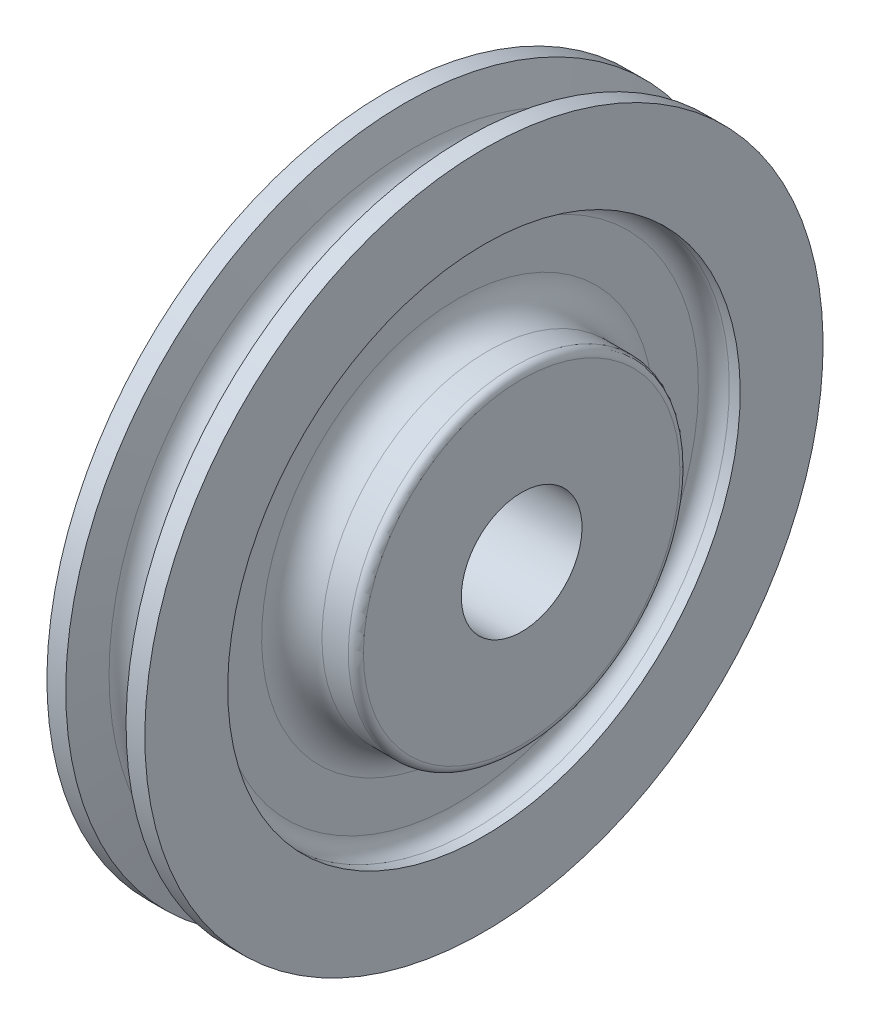
from build123d import *

# Parameters (mm, degrees)
SKETCH2_R          = 12.7127
CUT_EXTRUDE1_DEPTH = 37.5125


with BuildPart() as part:
    # Sketch1 → Revolve1 (revolve)
    with BuildSketch(Plane.XY):
        with BuildLine():
            Line((18.25625, 0), (-18.25625, 0))
            Line((-18.25625, 0), (-18.25625, 33.3375))
            ThreePointArc((-18.25625, 33.3375), (-17.791282015, 34.460032015), (-16.66875, 34.925))
            Line((-16.66875, 34.925), (-11.1125, 34.925))
            ThreePointArc((-11.1125, 34.925), (-6.622371939, 36.784871939), (-4.7625, 41.275))
            Line((-4.7625, 41.275), (-4.7625, 50.7238))
            ThreePointArc((-4.7625, 50.7238), (-5.714754433, 53.022745567), (-8.0137, 53.975))
            Line((-8.0137, 53.975), (-10.3124, 53.975))
            Line((-10.3124, 53.975), (-10.3124, 71.43115))
            Line((-10.3124, 71.43115), (-6.35, 71.43115))
            Line((-6.35, 71.43115), (-4.640755559, 64.017549491))
            ThreePointArc((-4.640755559, 64.017549491), (0, 60.325), (4.640755559, 64.017549491))
            Line((4.640755559, 64.017549491), (6.35, 71.43115))
            Line((6.35, 71.43115), (10.3124, 71.43115))
            Line((10.3124, 71.43115), (10.3124, 53.975))
            Line((10.3124, 53.975), (8.0137, 53.975))
            ThreePointArc((8.0137, 53.975), (5.714754433, 53.022745567), (4.7625, 50.7238))
            Line((4.7625, 50.7238), (4.7625, 41.275))
            ThreePointArc((4.7625, 41.275), (6.622371939, 36.784871939), (11.1125, 34.925))
            Line((11.1125, 34.925), (16.66875, 34.925))
            ThreePointArc((16.66875, 34.925), (17.791282015, 34.460032015), (18.25625, 33.3375))
            Line((18.25625, 33.3375), (18.25625, 0))
        make_face()
    revolve(axis=Axis((18.25625, 0, 0), (-1, 0, 0)))

    # Sketch2 → Cut-Extrude1 (cut, through all)
    with BuildSketch(Plane(origin=(18.25625, 0, 0), x_dir=(0, 0, -1), z_dir=(1, 0, 0))):
        with Locations(Location((0, 0, 0), (0, 0, 90))):  # turned: the seam where the file's is
            Circle(SKETCH2_R)
    extrude(amount=-CUT_EXTRUDE1_DEPTH, mode=Mode.SUBTRACT)


solid = part.part
